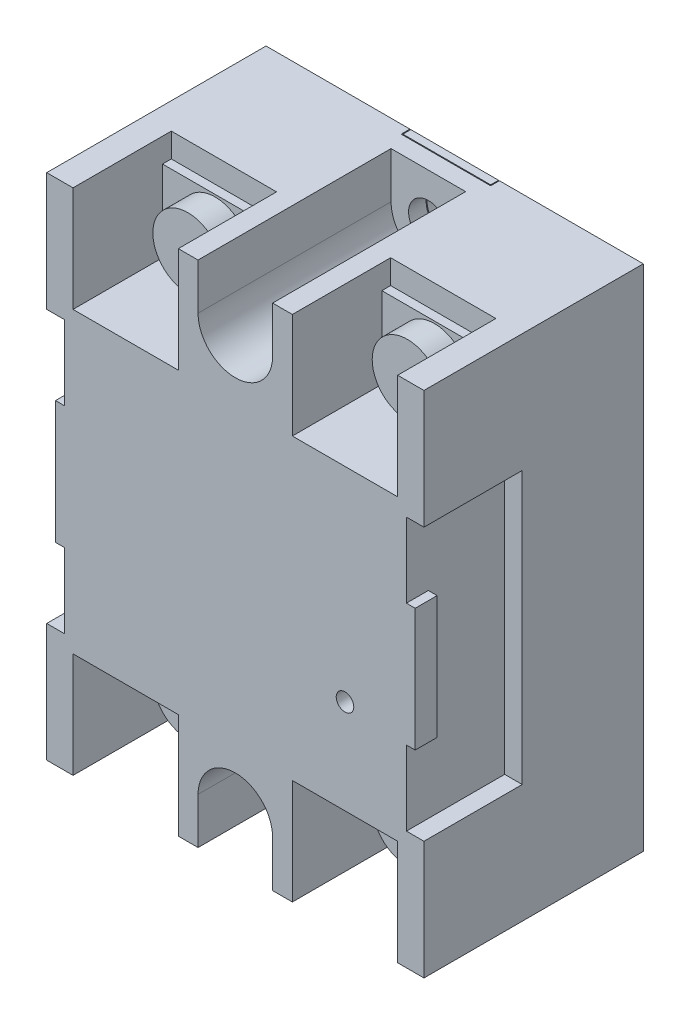
from build123d import *

# Parameters (mm, degrees)
SKETCH1_W                      = 8
SKETCH1_H                      = 1.4
BOSS_EXTRUDE1_DEPTH            = 1
SKETCH2_W                      = 34.6
SKETCH2_H                      = 58
BOSS_EXTRUDE2_DEPTH            = 24
SKETCH3_W                      = 26
SKETCH3_H                      = 55
BOSS_EXTRUDE3_DEPTH            = 1
BOSS_EXTRUDE4_DEPTH            = 1
SKETCH5_W                      = 8
SKETCH5_H                      = 1.4
BOSS_EXTRUDE5_DEPTH            = 1
SKETCH6_W                      = 10.2
SKETCH6_H                      = 8.5
CUT_EXTRUDE1_DEPTH             = 0.1
SKETCH7_W                      = 10.2
SKETCH7_H                      = 8.5
CUT_EXTRUDE2_DEPTH             = 0.1
SKETCH8_W                      = 25
SKETCH8_H                      = 58
BOSS_EXTRUDE6_DEPTH            = 8.4
SKETCH9_W                      = 10
SKETCH9_H                      = 0.9
BOSS_EXTRUDE7_DEPTH            = 1.5
SKETCH10_W                     = 10
SKETCH10_H                     = 0.9
BOSS_EXTRUDE8_DEPTH            = 1.5
SKETCH11_W                     = 12
SKETCH11_H                     = 11.2
CUT_EXTRUDE3_DEPTH             = 12
SKETCH12_W                     = 1
SKETCH12_H                     = 8.5
BOSS_EXTRUDE9_DEPTH            = 12
SKETCH13_W                     = 12
SKETCH13_H                     = 11.2
CUT_EXTRUDE4_DEPTH             = 12
SKETCH14_W                     = 1
SKETCH14_H                     = 8.5
BOSS_EXTRUDE10_DEPTH           = 12
SKETCH15_W                     = 12
SKETCH15_H                     = 11.2
CUT_EXTRUDE5_DEPTH             = 12
SKETCH16_W                     = 1
SKETCH16_H                     = 8.5
BOSS_EXTRUDE11_DEPTH           = 12
SKETCH17_W                     = 12
SKETCH17_H                     = 11.2
CUT_EXTRUDE6_DEPTH             = 12
SKETCH18_W                     = 1
SKETCH18_H                     = 8.5
BOSS_EXTRUDE12_DEPTH           = 12
CUT_EXTRUDE7_DEPTH             = 22
CUT_EXTRUDE8_DEPTH             = 25
CUT_EXTRUDE9_DEPTH             = 1.9
SKETCH22_W                     = 11.2
SKETCH22_H                     = 31
CUT_EXTRUDE10_DEPTH            = 2
SKETCH23_W                     = 2.5
SKETCH23_H                     = 14
BOSS_EXTRUDE13_DEPTH           = 1
SKETCH24_W                     = 11.2
SKETCH24_H                     = 31
CUT_EXTRUDE11_DEPTH            = 2
SKETCH25_W                     = 2.5
SKETCH25_H                     = 14
BOSS_EXTRUDE14_DEPTH           = 1
CUT_EXTRUDE12_DEPTH            = 22
SKETCH27_W                     = 4
SKETCH27_H                     = 3.1
SKETCH28_W                     = 4
SKETCH28_H                     = 3.1
SKETCH29_W                     = 4
SKETCH29_H                     = 3.1
SKETCH30_W                     = 4
SKETCH30_H                     = 3.1
F_2_0_2_DIAMETER_HOLE1_D       = 2
F_2_0_2_DIAMETER_HOLE1_DEPTH   = 1.5
F_4_5_4_5_DIAMETER_HOLE1_D     = 4.5
F_4_5_4_5_DIAMETER_HOLE1_DEPTH = 0.9
F_4_5_4_5_DIAMETER_HOLE2_D     = 4.5
F_4_5_4_5_DIAMETER_HOLE2_DEPTH = 24


with BuildPart() as part:
    # Sketch1 → Boss-Extrude1 (new body)
    with BuildSketch(Plane(origin=(0, 0, 0), x_dir=(-1, 0, 0), z_dir=(0, 0, -1))):
        with Locations((-9.1, 4.55)):
            Rectangle(SKETCH1_W, SKETCH1_H)
    extrude(amount=-BOSS_EXTRUDE1_DEPTH)

    # Sketch2 → Boss-Extrude2 (add)
    with BuildSketch(Plane(origin=(0, 0, 1), x_dir=(-1, 0, 0), z_dir=(0, 0, -1))):
        with Locations((4.2, -23.75)):
            Rectangle(SKETCH2_W, SKETCH2_H)
    extrude(amount=-BOSS_EXTRUDE2_DEPTH)

    # Sketch3 → Boss-Extrude3 (add)
    with BuildSketch(Plane(origin=(0, 0, 1), x_dir=(-1, 0, 0), z_dir=(0, 0, -1))):
        with Locations((0, -23.75)):
            Rectangle(SKETCH3_W, SKETCH3_H)
    extrude(amount=BOSS_EXTRUDE3_DEPTH)

    # Sketch4 → Boss-Extrude4 (add)
    with BuildSketch(Plane(origin=(0, 0, 1), x_dir=(-1, 0, 0), z_dir=(0, 0, -1))):
        Polygon((5.1, 5.25), (21.5, 5.25), (21.5, -52.75), (5.1, -52.75), (5.1, -51.35), (13.1, -51.35), (13.1, 3.85), (5.1, 3.85), align=None)
    extrude(amount=BOSS_EXTRUDE4_DEPTH)

    # Sketch5 → Boss-Extrude5 (add)
    with BuildSketch(Plane(origin=(0, 0, 1), x_dir=(-1, 0, 0), z_dir=(0, 0, -1))):
        with Locations((-9.1, -52.05)):
            Rectangle(SKETCH5_W, SKETCH5_H)
    extrude(amount=BOSS_EXTRUDE5_DEPTH)

    # Sketch6 → Cut-Extrude1 (cut)
    with BuildSketch(Plane.XY.offset(1)):
        with Locations((0, -0.5)):
            Rectangle(SKETCH6_W, SKETCH6_H)
    extrude(amount=-CUT_EXTRUDE1_DEPTH, mode=Mode.SUBTRACT)

    # Sketch7 → Cut-Extrude2 (cut)
    with BuildSketch(Plane.XY.offset(1)):
        with Locations((0, -47)):
            Rectangle(SKETCH7_W, SKETCH7_H)
    extrude(amount=-CUT_EXTRUDE2_DEPTH, mode=Mode.SUBTRACT)

    # Sketch8 → Boss-Extrude6 (add)
    with BuildSketch(Plane(origin=(13.1, 0, 0), x_dir=(0, 0, -1), z_dir=(1, 0, 0))):
        with Locations((-12.5, -23.75)):
            Rectangle(SKETCH8_W, SKETCH8_H)
    extrude(amount=BOSS_EXTRUDE6_DEPTH)

    # Sketch9 → Boss-Extrude7 (add)
    with BuildSketch(Plane.XZ.offset(51.25)):
        with Locations((0, 0.45)):
            Rectangle(SKETCH9_W, SKETCH9_H)
    extrude(amount=BOSS_EXTRUDE7_DEPTH)

    # Sketch10 → Boss-Extrude8 (add)
    with BuildSketch(Plane(origin=(0, 3.75, 0), x_dir=(-1, 0, 0), z_dir=(0, 1, 0))):
        with Locations((0, 0.45)):
            Rectangle(SKETCH10_W, SKETCH10_H)
    extrude(amount=BOSS_EXTRUDE8_DEPTH)

    # Sketch11 → Cut-Extrude3 (cut)
    with BuildSketch(Plane(origin=(0, 5.25, 0), x_dir=(-1, 0, 0), z_dir=(0, 1, 0))):
        with Locations((-12.5, 19.4)):
            Rectangle(SKETCH11_W, SKETCH11_H)
    extrude(amount=-CUT_EXTRUDE3_DEPTH, mode=Mode.SUBTRACT)

    # Sketch12 → Boss-Extrude9 (add)
    with BuildSketch(Plane(origin=(6.5, 0, 0), x_dir=(0, 0, -1), z_dir=(1, 0, 0))):
        with Locations((-14.3, -1.75)):
            Rectangle(SKETCH12_W, SKETCH12_H)
    extrude(amount=BOSS_EXTRUDE9_DEPTH)

    # Sketch13 → Cut-Extrude4 (cut)
    with BuildSketch(Plane(origin=(0, 5.25, 0), x_dir=(-1, 0, 0), z_dir=(0, 1, 0))):
        with Locations((12.5, 19.4)):
            Rectangle(SKETCH13_W, SKETCH13_H)
    extrude(amount=-CUT_EXTRUDE4_DEPTH, mode=Mode.SUBTRACT)

    # Sketch14 → Boss-Extrude10 (add)
    with BuildSketch(Plane(origin=(-18.5, 0, 0), x_dir=(0, 0, -1), z_dir=(1, 0, 0))):
        with Locations((-14.3, -1.75)):
            Rectangle(SKETCH14_W, SKETCH14_H)
    extrude(amount=BOSS_EXTRUDE10_DEPTH)

    # Sketch15 → Cut-Extrude5 (cut)
    with BuildSketch(Plane.XZ.offset(52.75)):
        with Locations((12.5, 19.4)):
            Rectangle(SKETCH15_W, SKETCH15_H)
    extrude(amount=-CUT_EXTRUDE5_DEPTH, mode=Mode.SUBTRACT)

    # Sketch16 → Boss-Extrude11 (add)
    with BuildSketch(Plane.ZY.offset(-18.5)):
        with Locations((14.3, -45.75)):
            Rectangle(SKETCH16_W, SKETCH16_H)
    extrude(amount=BOSS_EXTRUDE11_DEPTH)

    # Sketch17 → Cut-Extrude6 (cut)
    with BuildSketch(Plane.XZ.offset(52.75)):
        with Locations((-12.5, 19.4)):
            Rectangle(SKETCH17_W, SKETCH17_H)
    extrude(amount=-CUT_EXTRUDE6_DEPTH, mode=Mode.SUBTRACT)

    # Sketch18 → Boss-Extrude12 (add)
    with BuildSketch(Plane.ZY.offset(6.5)):
        with Locations((14.3, -45.75)):
            Rectangle(SKETCH18_W, SKETCH18_H)
    extrude(amount=BOSS_EXTRUDE12_DEPTH)

    # Sketch19 → Cut-Extrude7 (cut)
    with BuildSketch(Plane.XY.offset(25)):
        with BuildLine():
            Line((4.25, -52.75), (4.25, -47.5))
            ThreePointArc((4.25, -47.5), (0, -43.25), (-4.25, -47.5))
            Line((-4.25, -47.5), (-4.25, -52.75))
            Line((-4.25, -52.75), (4.25, -52.75))
        make_face()
    extrude(amount=-CUT_EXTRUDE7_DEPTH, mode=Mode.SUBTRACT)

    # Sketch20 → Cut-Extrude8 (cut, through all)
    with BuildSketch(Plane(origin=(0, 0, 1), x_dir=(-1, 0, 0), z_dir=(0, 0, -1))):
        with BuildLine():
            Line((-2.25, -52.75), (2.25, -52.75))
            Line((2.25, -52.75), (2.25, -47.5))
            ThreePointArc((2.25, -47.5), (0, -45.25), (-2.25, -47.5))
            Line((-2.25, -47.5), (-2.25, -52.75))
        make_face()
    extrude(amount=-CUT_EXTRUDE8_DEPTH, mode=Mode.SUBTRACT)

    # Sketch21 → Cut-Extrude9 (cut, through all)
    with BuildSketch(Plane.XY.offset(0.9)):
        with BuildLine():
            Line((-2.25, -52.75), (2.25, -52.75))
            Line((2.25, -52.75), (2.25, -47.5))
            ThreePointArc((2.25, -47.5), (0, -45.25), (-2.25, -47.5))
            Line((-2.25, -47.5), (-2.25, -52.75))
        make_face()
    extrude(amount=-CUT_EXTRUDE9_DEPTH, mode=Mode.SUBTRACT)

    # Sketch22 → Cut-Extrude10 (cut)
    with BuildSketch(Plane(origin=(21.5, 0, 0), x_dir=(0, 0, -1), z_dir=(1, 0, 0))):
        with Locations((-19.4, -23.75)):
            Rectangle(SKETCH22_W, SKETCH22_H)
    extrude(amount=-CUT_EXTRUDE10_DEPTH, mode=Mode.SUBTRACT)

    # Sketch23 → Boss-Extrude13 (add)
    with BuildSketch(Plane(origin=(19.5, 0, 0), x_dir=(0, 0, -1), z_dir=(1, 0, 0))):
        with Locations((-23.75, -23.75)):
            Rectangle(SKETCH23_W, SKETCH23_H)
    extrude(amount=BOSS_EXTRUDE13_DEPTH)

    # Sketch24 → Cut-Extrude11 (cut)
    with BuildSketch(Plane.ZY.offset(21.5)):
        with Locations((19.4, -23.75)):
            Rectangle(SKETCH24_W, SKETCH24_H)
    extrude(amount=-CUT_EXTRUDE11_DEPTH, mode=Mode.SUBTRACT)

    # Sketch25 → Boss-Extrude14 (add)
    with BuildSketch(Plane.ZY.offset(19.5)):
        with Locations((23.75, -23.75)):
            Rectangle(SKETCH25_W, SKETCH25_H)
    extrude(amount=BOSS_EXTRUDE14_DEPTH)

    # Sketch26 → Cut-Extrude12 (cut)
    with BuildSketch(Plane.XY.offset(25)):
        with BuildLine():
            Line((-4.25, 5.25), (-4.25, 0))
            ThreePointArc((-4.25, 0), (0, -4.25), (4.25, 0))
            Line((4.25, 0), (4.25, 5.25))
            Line((4.25, 5.25), (-4.25, 5.25))
        make_face()
    extrude(amount=-CUT_EXTRUDE12_DEPTH, mode=Mode.SUBTRACT)

    # Sketch27 → Revolve1 (revolve)
    with BuildSketch(Plane.XZ.offset(45.75)):
        with Locations((14.5, 16.35)):
            Rectangle(SKETCH27_W, SKETCH27_H)
    revolve(axis=Axis((12.5, -45.75, 17.9), (0, 0, -1)))

    # Sketch28 → Revolve2 (revolve)
    with BuildSketch(Plane.XZ.offset(1.75)):
        with Locations((14.5, 16.35)):
            Rectangle(SKETCH28_W, SKETCH28_H)
    revolve(axis=Axis((12.5, -1.75, 17.9), (0, 0, -1)))

    # Sketch29 → Revolve3 (revolve)
    with BuildSketch(Plane.XZ.offset(45.75)):
        with Locations((-10.5, 16.35)):
            Rectangle(SKETCH29_W, SKETCH29_H)
    revolve(axis=Axis((-12.5, -45.75, 17.9), (0, 0, -1)))

    # Sketch30 → Revolve4 (revolve)
    with BuildSketch(Plane.XZ.offset(1.75)):
        with Locations((-10.5, 16.35)):
            Rectangle(SKETCH30_W, SKETCH30_H)
    revolve(axis=Axis((-12.5, -1.75, 17.9), (0, 0, -1)))

    # Ø2.0 (2) Diameter Hole1
    with Locations(Plane.XY.offset(25)):
        with Locations((12.5, -30)):
            Hole(F_2_0_2_DIAMETER_HOLE1_D / 2, depth=F_2_0_2_DIAMETER_HOLE1_DEPTH)

    # Ø4.5 (4.5) Diameter Hole1
    with Locations(Plane(origin=(0, 0, 0), x_dir=(-1, 0, 0), z_dir=(0, 0, -1))):
        with Locations((0, 0)):
            Hole(F_4_5_4_5_DIAMETER_HOLE1_D / 2, depth=F_4_5_4_5_DIAMETER_HOLE1_DEPTH)

    # Ø4.5 (4.5) Diameter Hole2
    with Locations(Plane(origin=(0, 0, 1), x_dir=(-1, 0, 0), z_dir=(0, 0, -1))):
        with Locations((0, 0)):
            Hole(F_4_5_4_5_DIAMETER_HOLE2_D / 2, depth=F_4_5_4_5_DIAMETER_HOLE2_DEPTH)


solid = part.part
